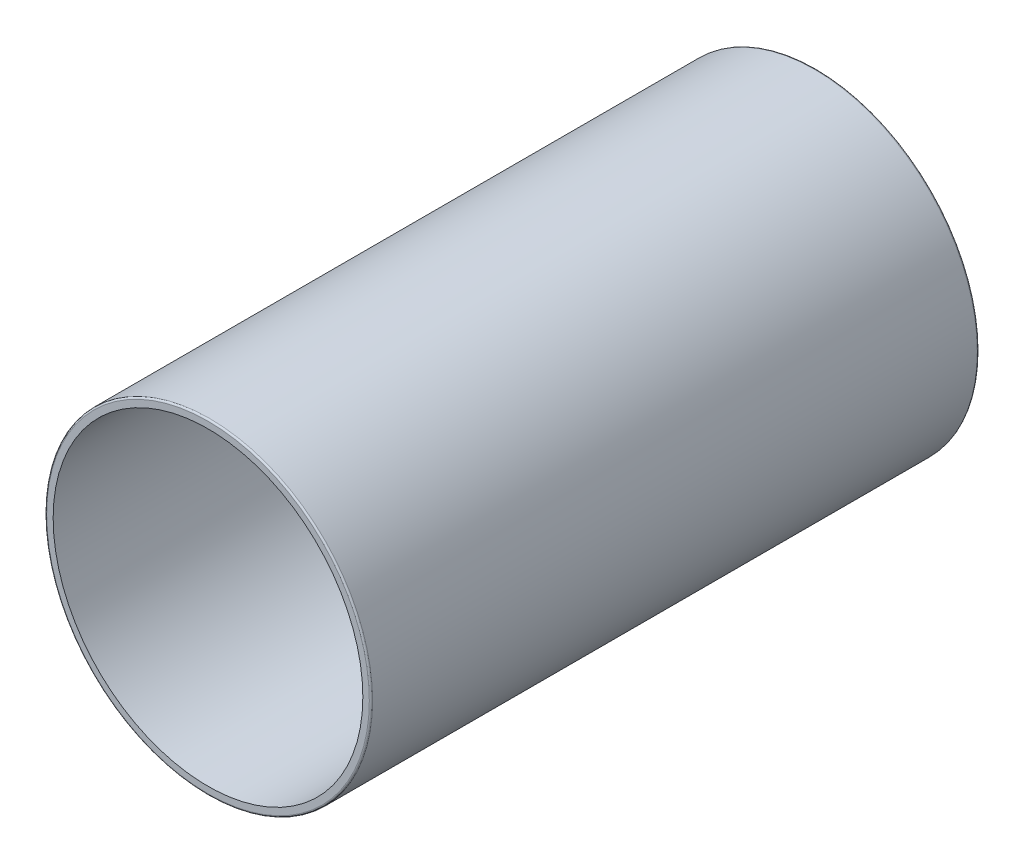
from build123d import *

# Parameters (mm, degrees)
SKETCH2_R           = 201
BOSS_EXTRUDE1_DEPTH = 750
SHELL1_T            = -10
SKETCH3_R           = 192.25
CUT_EXTRUDE1_DEPTH  = 793.718108788
FILLET2_R           = 2
FILLET3_R           = 2


with BuildPart() as part:
    # Sketch2 → Boss-Extrude1 (new body)
    with BuildSketch(Plane.XY):
        Circle(SKETCH2_R)
    extrude(amount=BOSS_EXTRUDE1_DEPTH)

    # Shell1
    shell1_openings = [part.faces().sort_by_distance(p)[0] for p in [
        (0, 0, 750),
    ]]
    offset(amount=SHELL1_T, openings=shell1_openings, kind=Kind.INTERSECTION)

    # Sketch3 → Cut-Extrude1 (cut, through all)
    with BuildSketch(Plane.XY.offset(10)):
        Circle(SKETCH3_R)
    extrude(amount=-CUT_EXTRUDE1_DEPTH, mode=Mode.SUBTRACT)

    # Fillet2
    fillet2_edges = [part.edges().sort_by_distance(p)[0] for p in [
        (-201, 0, 0),
    ]]
    fillet(fillet2_edges, radius=FILLET2_R)

    # Fillet3
    fillet3_edges = [part.edges().sort_by_distance(p)[0] for p in [
        (-201, 0, 750),
    ]]
    fillet(fillet3_edges, radius=FILLET3_R)


solid = part.part
